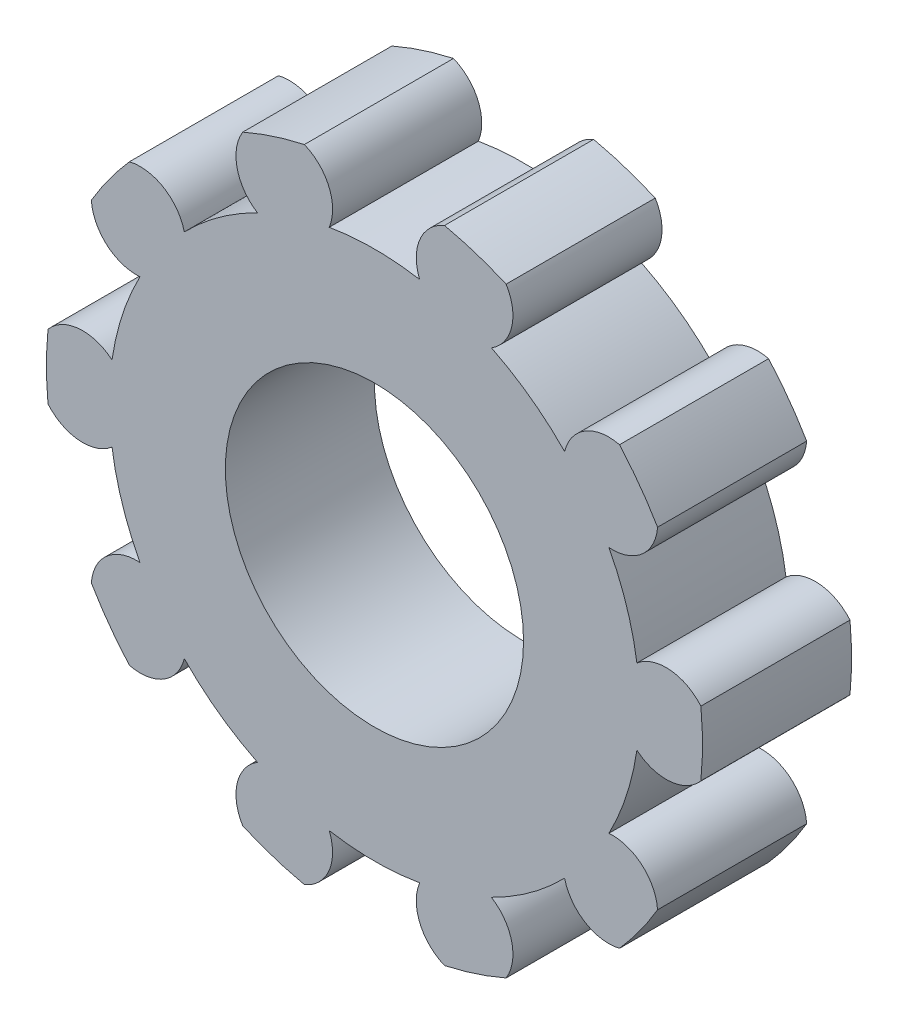
from build123d import *

# Parameters (mm, degrees)
SKETCH1_R           = 13.2
SKETCH1_R_2         = 6
BOSS_EXTRUDE1_DEPTH = 6
CUT_EXTRUDE1_DEPTH  = 7
CIRPATTERN2_COUNT   = 10


with BuildPart() as part:
    # Sketch1 → Boss-Extrude1 (new body)
    with BuildSketch(Plane.XY):
        Circle(SKETCH1_R)
        Circle(SKETCH1_R_2, mode=Mode.SUBTRACT)
    extrude(amount=BOSS_EXTRUDE1_DEPTH)

    # Sketch2 → Cut-Extrude1 (cut, through all)
    with BuildSketch(Plane.XY.offset(6)):
        with BuildLine():
            ThreePointArc((-2.819851171, 12.895287487), (0, 13.2), (2.819851171, 12.895287487))
            ThreePointArc((2.819851171, 12.895287487), (1.826256171, 11.910750525), (1.819851171, 10.512))
            ThreePointArc((1.819851171, 10.512), (0, 10.668364555), (-1.819851171, 10.512))
            ThreePointArc((-1.819851171, 10.512), (-1.826256171, 11.910750525), (-2.819851171, 12.895287487))
        make_face()
    cut_extrude1 = extrude(amount=-CUT_EXTRUDE1_DEPTH, mode=Mode.SUBTRACT)

    # CirPattern2: Cut-Extrude1 ×10 about axis
    cirpattern2_axis = Axis((0, 0, 0), (0, 0, 1))
    for i in range(1, CIRPATTERN2_COUNT):
        add(cut_extrude1.rotate(cirpattern2_axis, i * 360 / CIRPATTERN2_COUNT), mode=Mode.SUBTRACT)


solid = part.part
